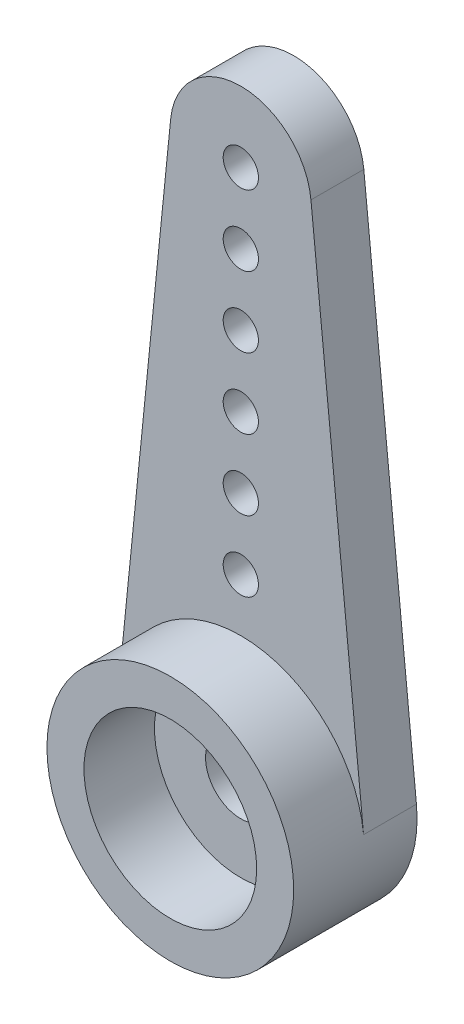
from build123d import *

# Parameters (mm, degrees)
ESQUISSE1_R             = 1
ESQUISSE1_R_2           = 0.5
BOSS_EXTRU_1_DEPTH      = 1.5
ESQUISSE3_R             = 3.5
ESQUISSE3_R_2           = 1
BOSS_EXTRU_2_DEPTH      = 2
ESQUISSE4_R             = 2.45
ENL_V_MAT_EXTRU_1_DEPTH = 2


with BuildPart() as part:
    # Esquisse1 → Boss.-Extru.1 (new body)
    with BuildSketch(Plane.XY):
        with BuildLine():
            Line((-1.989974874, 15.2), (-3.48245603, 0.35))
            ThreePointArc((-3.48245603, 0.35), (0, -3.5), (3.48245603, 0.35))
            Line((3.48245603, 0.35), (1.989974874, 15.2))
            ThreePointArc((1.989974874, 15.2), (0, 17), (-1.989974874, 15.2))
        make_face()
        Circle(ESQUISSE1_R, mode=Mode.SUBTRACT)
        with Locations((0, 15)):
            Circle(ESQUISSE1_R_2, mode=Mode.SUBTRACT)
        with Locations((0, 13)):
            Circle(ESQUISSE1_R_2, mode=Mode.SUBTRACT)
        with Locations((0, 11)):
            Circle(ESQUISSE1_R_2, mode=Mode.SUBTRACT)
        with Locations((0, 9)):
            Circle(ESQUISSE1_R_2, mode=Mode.SUBTRACT)
        with Locations((0, 7)):
            Circle(ESQUISSE1_R_2, mode=Mode.SUBTRACT)
        with Locations((0, 5)):
            Circle(ESQUISSE1_R_2, mode=Mode.SUBTRACT)
    extrude(amount=BOSS_EXTRU_1_DEPTH)

    # Esquisse3 → Boss.-Extru.2 (add)
    with BuildSketch(Plane.XY.offset(1.5)):
        Circle(ESQUISSE3_R)
        Circle(ESQUISSE3_R_2, mode=Mode.SUBTRACT)
    extrude(amount=BOSS_EXTRU_2_DEPTH)

    # Esquisse4 → Enlèv. mat.-Extru.1 (cut)
    with BuildSketch(Plane.XY.offset(3.5)):
        Circle(ESQUISSE4_R)
    extrude(amount=-ENL_V_MAT_EXTRU_1_DEPTH, mode=Mode.SUBTRACT)


solid = part.part
